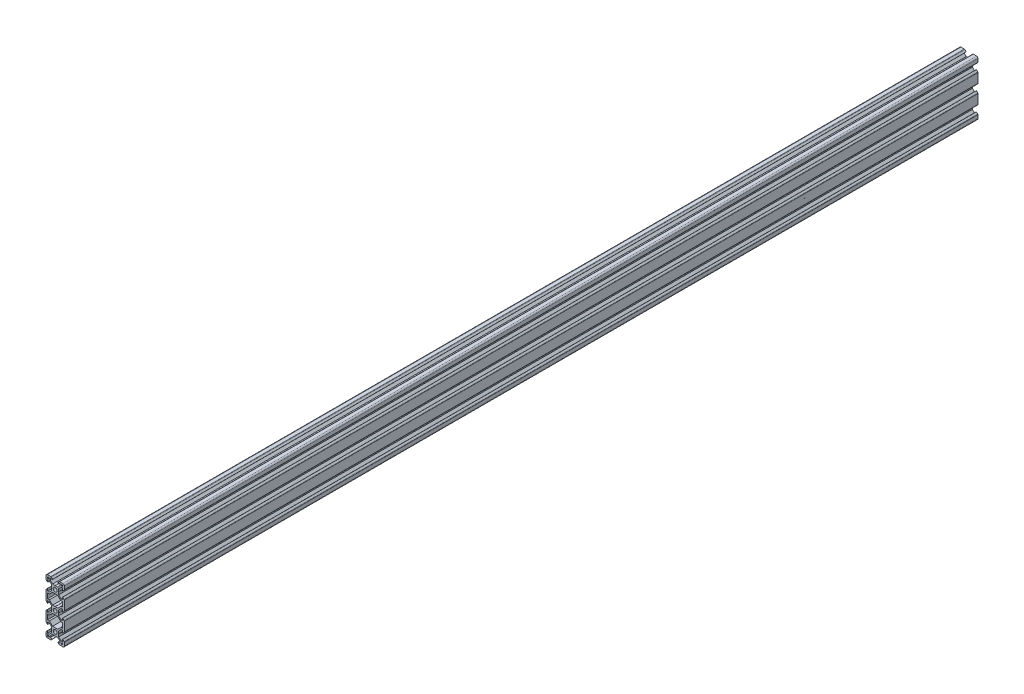
from build123d import *

# Parameters (mm, degrees)
SKETCH6_R           = 2.1
BOSS_EXTRUDE1_DEPTH = 1000


with BuildPart() as part:
    # Sketch6 → Boss-Extrude1 (new body)
    with BuildSketch(Plane.XY):
        with BuildLine():
            Line((-0.1, 3.9), (0, 3.8))
            Line((0, 3.8), (0.1, 3.9))
            Line((0.1, 3.9), (2.840365134, 3.9))
            Line((2.840365134, 3.9), (5.5, 6.558825842))
            Line((5.5, 6.558825842), (5.5, 8.197505675))
            Line((5.5, 8.197505675), (2.89, 8.197505675))
            Line((2.89, 8.197505675), (2.89, 8.307505675))
            Line((2.89, 8.307505675), (4.348614357, 9.766120032))
            ThreePointArc((4.348614357, 9.766120032), (4.604908803, 9.937370505), (4.907228714, 9.997505675))
            Line((4.907228714, 9.997505675), (8.5, 9.997505675))
            ThreePointArc((8.5, 9.997505675), (9.560660172, 9.558165846), (10, 8.497505675))
            Line((10, 8.497505675), (10, 4.904734389))
            ThreePointArc((10, 4.904734389), (9.939864831, 4.602414477), (9.768614357, 4.346120032))
            Line((9.768614357, 4.346120032), (8.31, 2.887505675))
            Line((8.31, 2.887505675), (8.2, 2.887505675))
            Line((8.2, 2.887505675), (8.2, 5.497505675))
            Line((8.2, 5.497505675), (6.56, 5.497505675))
            Line((6.56, 5.497505675), (3.9, 2.83831481))
            Line((3.9, 2.83831481), (3.9, 0.1))
            Line((3.9, 0.1), (3.8, 0))
            Line((3.8, 0), (3.9, -0.1))
            Line((3.9, -0.1), (3.9, -2.84))
            Line((3.9, -2.84), (6.56, -5.5))
            Line((6.56, -5.5), (8.21, -5.5))
            Line((8.21, -5.5), (8.21, -2.89))
            Line((8.21, -2.89), (8.31, -2.89))
            Line((8.31, -2.89), (9.765685425, -4.345685425))
            ThreePointArc((9.765685425, -4.345685425), (9.939103626, -4.605224104), (10, -4.91137085))
            Line((10, -4.91137085), (10, -15.08862915))
            ThreePointArc((10, -15.08862915), (9.939103626, -15.394775896), (9.765685425, -15.654314575))
            Line((9.765685425, -15.654314575), (8.31, -17.11))
            Line((8.31, -17.11), (8.21, -17.11))
            Line((8.21, -17.11), (8.21, -14.5))
            Line((8.21, -14.5), (6.56, -14.5))
            Line((6.56, -14.5), (3.9, -17.16))
            Line((3.9, -17.16), (3.9, -19.9))
            Line((3.9, -19.9), (3.8, -20))
            Line((3.8, -20), (3.9, -20.1))
            Line((3.9, -20.1), (3.9, -22.84))
            Line((3.9, -22.84), (6.56, -25.5))
            Line((6.56, -25.5), (8.21, -25.5))
            Line((8.21, -25.5), (8.21, -22.89))
            Line((8.21, -22.89), (8.31, -22.89))
            Line((8.31, -22.89), (9.765685425, -24.345685425))
            ThreePointArc((9.765685425, -24.345685425), (9.939103626, -24.605224104), (10, -24.91137085))
            Line((10, -24.91137085), (10, -35.08862915))
            ThreePointArc((10, -35.08862915), (9.939103626, -35.394775896), (9.765685425, -35.654314575))
            Line((9.765685425, -35.654314575), (8.31, -37.11))
            Line((8.31, -37.11), (8.21, -37.11))
            Line((8.21, -37.11), (8.21, -34.5))
            Line((8.21, -34.5), (6.56, -34.5))
            Line((6.56, -34.5), (3.9, -37.16))
            Line((3.9, -37.16), (3.9, -39.9))
            Line((3.9, -39.9), (3.8, -40))
            Line((3.8, -40), (3.9, -40.1))
            Line((3.9, -40.1), (3.9, -42.83831481))
            Line((3.9, -42.83831481), (6.56, -45.497505675))
            Line((6.56, -45.497505675), (8.2, -45.497505675))
            Line((8.2, -45.497505675), (8.2, -42.887505675))
            Line((8.2, -42.887505675), (8.31, -42.887505675))
            Line((8.31, -42.887505675), (9.768614357, -44.346120032))
            ThreePointArc((9.768614357, -44.346120032), (9.939864831, -44.602414477), (10, -44.904734389))
            Line((10, -44.904734389), (10, -48.497505675))
            ThreePointArc((10, -48.497505675), (9.560660172, -49.558165846), (8.5, -49.997505675))
            Line((8.5, -49.997505675), (4.907228714, -49.997505675))
            ThreePointArc((4.907228714, -49.997505675), (4.604908803, -49.937370505), (4.348614357, -49.766120032))
            Line((4.348614357, -49.766120032), (2.89, -48.307505675))
            Line((2.89, -48.307505675), (2.89, -48.197505675))
            Line((2.89, -48.197505675), (5.5, -48.197505675))
            Line((5.5, -48.197505675), (5.5, -46.558825842))
            Line((5.5, -46.558825842), (2.840365134, -43.9))
            Line((2.840365134, -43.9), (0.1, -43.9))
            Line((0.1, -43.9), (0, -43.8))
            Line((0, -43.8), (-0.1, -43.9))
            Line((-0.1, -43.9), (-2.840365134, -43.9))
            Line((-2.840365134, -43.9), (-5.5, -46.558825842))
            Line((-5.5, -46.558825842), (-5.5, -48.197505675))
            Line((-5.5, -48.197505675), (-2.89, -48.197505675))
            Line((-2.89, -48.197505675), (-2.89, -48.307505675))
            Line((-2.89, -48.307505675), (-4.348614357, -49.766120032))
            ThreePointArc((-4.348614357, -49.766120032), (-4.604908803, -49.937370505), (-4.907228714, -49.997505675))
            Line((-4.907228714, -49.997505675), (-8.5, -49.997505675))
            ThreePointArc((-8.5, -49.997505675), (-9.560660172, -49.558165846), (-10, -48.497505675))
            Line((-10, -48.497505675), (-10, -44.904734389))
            ThreePointArc((-10, -44.904734389), (-9.939864831, -44.602414477), (-9.768614357, -44.346120032))
            Line((-9.768614357, -44.346120032), (-8.31, -42.887505675))
            Line((-8.31, -42.887505675), (-8.2, -42.887505675))
            Line((-8.2, -42.887505675), (-8.2, -45.497505675))
            Line((-8.2, -45.497505675), (-6.56, -45.497505675))
            Line((-6.56, -45.497505675), (-3.9, -42.83831481))
            Line((-3.9, -42.83831481), (-3.9, -40.1))
            Line((-3.9, -40.1), (-3.8, -40))
            Line((-3.8, -40), (-3.9, -39.9))
            Line((-3.9, -39.9), (-3.9, -37.16))
            Line((-3.9, -37.16), (-6.56, -34.5))
            Line((-6.56, -34.5), (-8.21, -34.5))
            Line((-8.21, -34.5), (-8.21, -37.11))
            Line((-8.21, -37.11), (-8.31, -37.11))
            Line((-8.31, -37.11), (-9.765685425, -35.654314575))
            ThreePointArc((-9.765685425, -35.654314575), (-9.939103626, -35.394775896), (-10, -35.08862915))
            Line((-10, -35.08862915), (-10, -24.91137085))
            ThreePointArc((-10, -24.91137085), (-9.939103626, -24.605224104), (-9.765685425, -24.345685425))
            Line((-9.765685425, -24.345685425), (-8.31, -22.89))
            Line((-8.31, -22.89), (-8.21, -22.89))
            Line((-8.21, -22.89), (-8.21, -25.5))
            Line((-8.21, -25.5), (-6.56, -25.5))
            Line((-6.56, -25.5), (-3.9, -22.84))
            Line((-3.9, -22.84), (-3.9, -20.1))
            Line((-3.9, -20.1), (-3.8, -20))
            Line((-3.8, -20), (-3.9, -19.9))
            Line((-3.9, -19.9), (-3.9, -17.16))
            Line((-3.9, -17.16), (-6.56, -14.5))
            Line((-6.56, -14.5), (-8.21, -14.5))
            Line((-8.21, -14.5), (-8.21, -17.11))
            Line((-8.21, -17.11), (-8.31, -17.11))
            Line((-8.31, -17.11), (-9.765685425, -15.654314575))
            ThreePointArc((-9.765685425, -15.654314575), (-9.939103626, -15.394775896), (-10, -15.08862915))
            Line((-10, -15.08862915), (-10, -4.91137085))
            ThreePointArc((-10, -4.91137085), (-9.939103626, -4.605224104), (-9.765685425, -4.345685425))
            Line((-9.765685425, -4.345685425), (-8.31, -2.89))
            Line((-8.31, -2.89), (-8.21, -2.89))
            Line((-8.21, -2.89), (-8.21, -5.5))
            Line((-8.21, -5.5), (-6.56, -5.5))
            Line((-6.56, -5.5), (-3.9, -2.84))
            Line((-3.9, -2.84), (-3.9, -0.1))
            Line((-3.9, -0.1), (-3.8, 0))
            Line((-3.8, 0), (-3.9, 0.1))
            Line((-3.9, 0.1), (-3.9, 2.83831481))
            Line((-3.9, 2.83831481), (-6.56, 5.497505675))
            Line((-6.56, 5.497505675), (-8.2, 5.497505675))
            Line((-8.2, 5.497505675), (-8.2, 2.887505675))
            Line((-8.2, 2.887505675), (-8.31, 2.887505675))
            Line((-8.31, 2.887505675), (-9.768614357, 4.346120032))
            ThreePointArc((-9.768614357, 4.346120032), (-9.939864831, 4.602414477), (-10, 4.904734389))
            Line((-10, 4.904734389), (-10, 8.497505675))
            ThreePointArc((-10, 8.497505675), (-9.560660172, 9.558165846), (-8.5, 9.997505675))
            Line((-8.5, 9.997505675), (-4.907228714, 9.997505675))
            ThreePointArc((-4.907228714, 9.997505675), (-4.604908803, 9.937370505), (-4.348614357, 9.766120032))
            Line((-4.348614357, 9.766120032), (-2.89, 8.307505675))
            Line((-2.89, 8.307505675), (-2.89, 8.197505675))
            Line((-2.89, 8.197505675), (-5.5, 8.197505675))
            Line((-5.5, 8.197505675), (-5.5, 6.558825842))
            Line((-5.5, 6.558825842), (-2.840365134, 3.9))
            Line((-2.840365134, 3.9), (-0.1, 3.9))
        make_face()
        Circle(SKETCH6_R, mode=Mode.SUBTRACT)
        with Locations((0, -20)):
            Circle(SKETCH6_R, mode=Mode.SUBTRACT)
        with Locations((0, -40)):
            Circle(SKETCH6_R, mode=Mode.SUBTRACT)
        Polygon((-7.66, 6.567505675), (-6.57, 7.657505675), (-6.57, 8.197505675), (-8.2, 8.197505675), (-8.2, 6.567505675), align=None, mode=Mode.SUBTRACT)
        Polygon((2.840365134, -3.9), (-2.840365134, -3.9), (-6.25, -7.309634866), (-8.21, -7.309634866), (-8.21, -12.7), (-6.25, -12.7), (-2.85, -16.1), (-0.1, -16.1), (0, -16.2), (0.1, -16.1), (2.85, -16.1), (6.25, -12.7), (8.21, -12.7), (8.21, -7.309634866), (6.25, -7.309634866), align=None, mode=Mode.SUBTRACT)
        Polygon((8.2, 6.567505675), (7.66, 6.567505675), (6.57, 7.657505675), (6.57, 8.197505675), (8.2, 8.197505675), align=None, mode=Mode.SUBTRACT)
        Polygon((7.66, -46.567505675), (6.57, -47.657505675), (6.57, -48.197505675), (8.2, -48.197505675), (8.2, -46.567505675), align=None, mode=Mode.SUBTRACT)
        Polygon((2.840365134, -36.1), (6.25, -32.690365134), (8.21, -32.690365134), (8.21, -27.3), (6.25, -27.3), (2.85, -23.9), (0.1, -23.9), (0, -23.8), (-0.1, -23.9), (-2.85, -23.9), (-6.25, -27.3), (-8.21, -27.3), (-8.21, -32.690365134), (-6.25, -32.690365134), (-2.840365134, -36.1), align=None, mode=Mode.SUBTRACT)
        Polygon((-8.2, -46.567505675), (-7.66, -46.567505675), (-6.57, -47.657505675), (-6.57, -48.197505675), (-8.2, -48.197505675), align=None, mode=Mode.SUBTRACT)
    extrude(amount=-BOSS_EXTRUDE1_DEPTH)


solid = part.part
